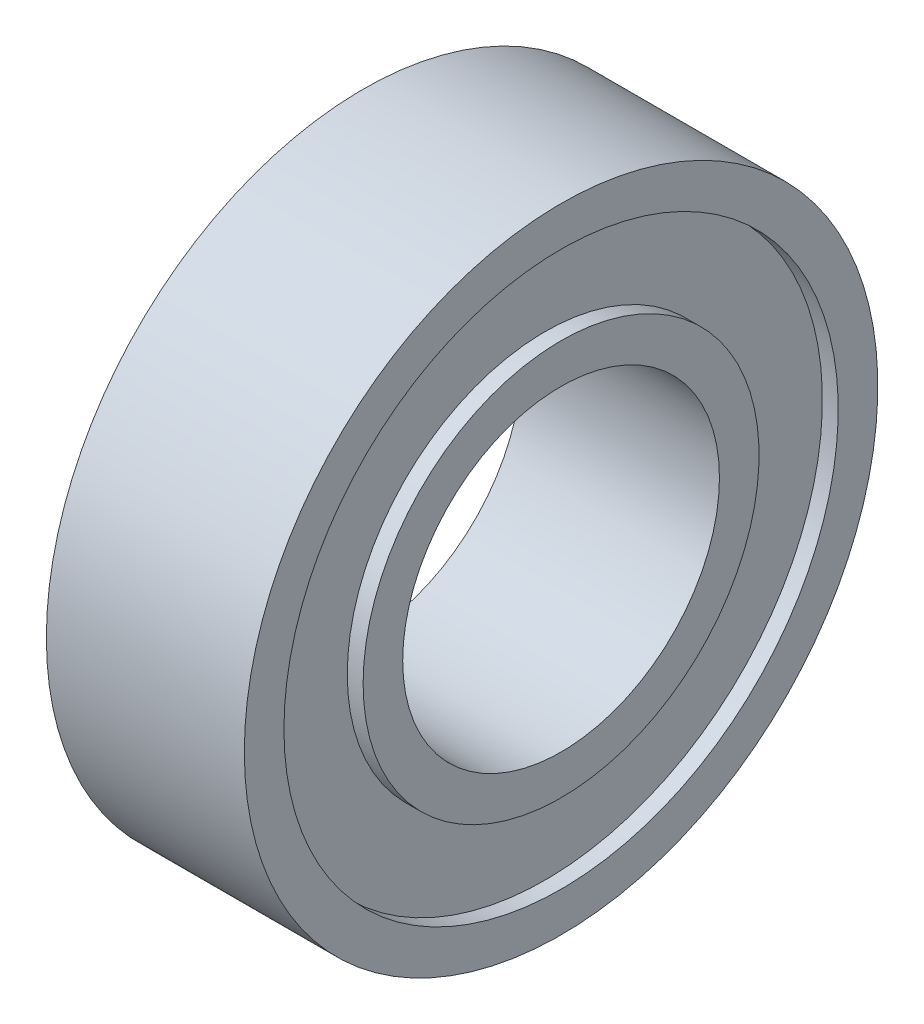
from build123d import *


with BuildPart() as part:
    # Sketch1 → Revolve1 (revolve)
    with BuildSketch(Plane.XY):
        Polygon((-2.5, 8), (2.5, 8), (2.5, 7), (2.1, 7), (2.1, 5), (2.5, 5), (2.5, 4), (-2.5, 4), (-2.5, 5), (-2.1, 5), (-2.1, 7), (-2.5, 7), align=None)
    revolve(axis=Axis((-2.5, 0, 0), (1, 0, 0)))


solid = part.part
